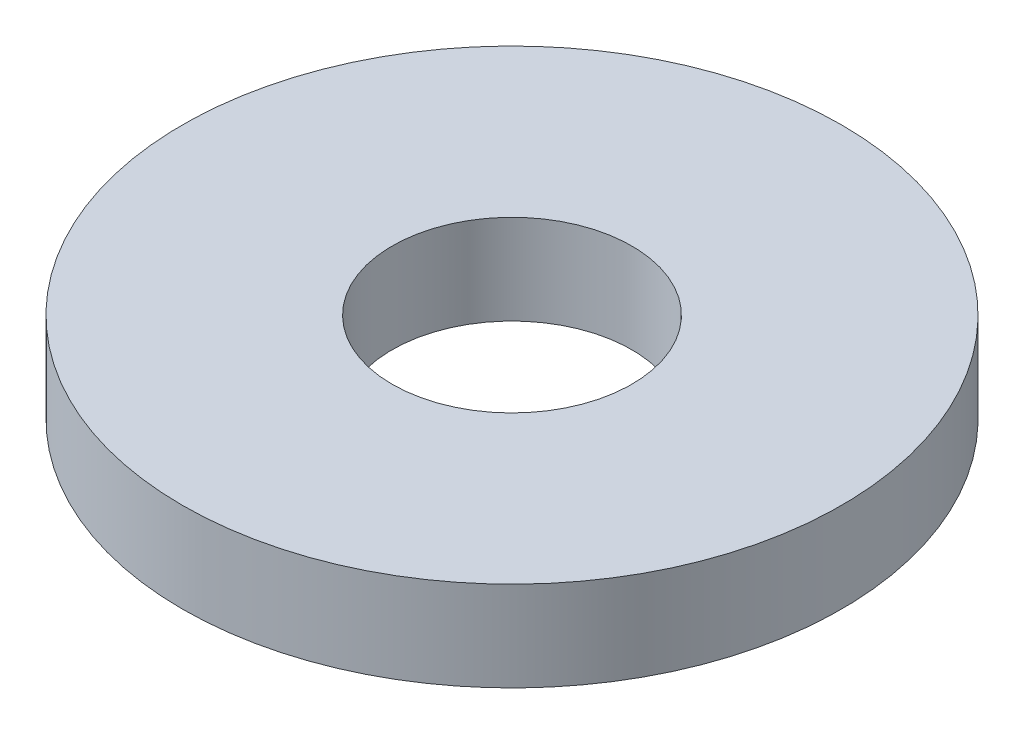
from build123d import *

# Parameters (mm, degrees)
SKETCH2_R           = 5.5
BOSS_EXTRUDE1_DEPTH = 1.5
SKETCH3_HOLE_R      = 2
CUT_EXTRUDE1_DEPTH  = 2.5


with BuildPart() as part:
    # Sketch2 → Boss-Extrude1 (new body)
    with BuildSketch(Plane(origin=(0, 0, 0), x_dir=(1, 0, 0), z_dir=(0, 1, 0))):
        with Locations(Location((0, 0, 0), (0, 0, 270))):  # turned: the seam where the file's is
            Circle(SKETCH2_R)
    extrude(amount=BOSS_EXTRUDE1_DEPTH)

    # Sketch3 Hole → Cut-Extrude1 (cut, through all)
    with BuildSketch(Plane(origin=(0, 1.5, 0), x_dir=(1, 0, 0), z_dir=(0, 1, 0))):
        with Locations(Location((0, 0, 0), (0, 0, 270))):  # turned: the seam where the file's is
            Circle(SKETCH3_HOLE_R)
    extrude(amount=-CUT_EXTRUDE1_DEPTH, mode=Mode.SUBTRACT)


solid = part.part
